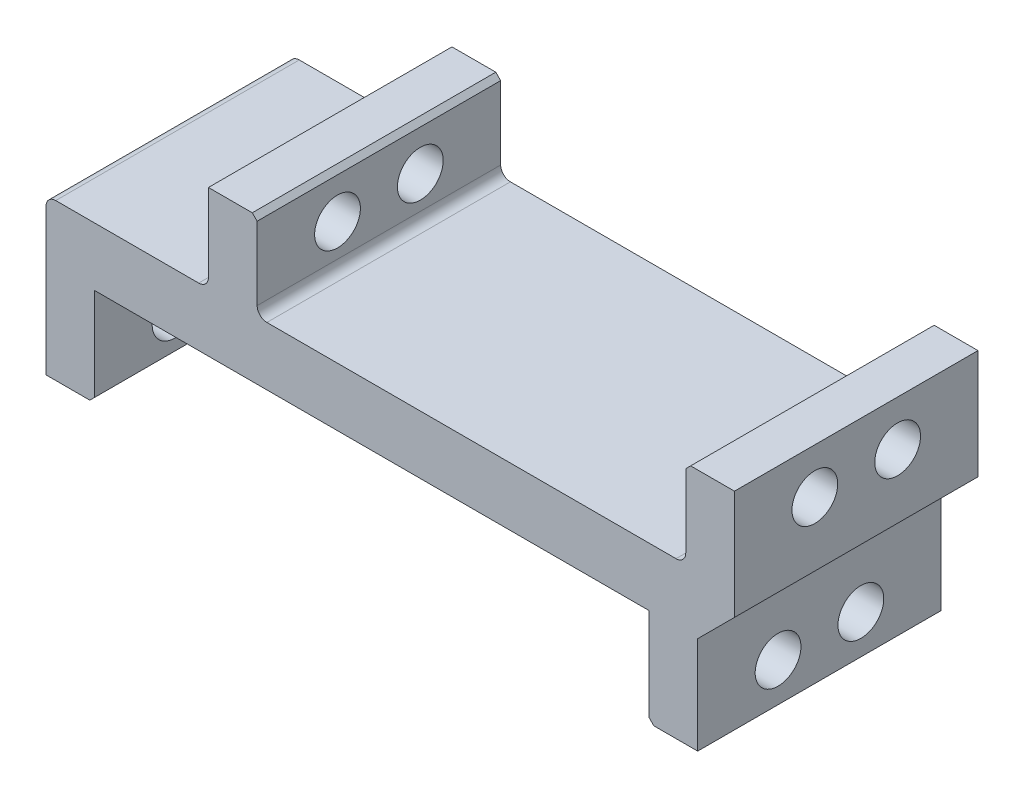
from build123d import *

# Parameters (mm, degrees)
BOSS_EXTRUDE3_DEPTH     = 12.5
SKETCH6_R               = 2.35
CUT_EXTRUDE1_DEPTH      = 38.225
CUT_EXTRUDE1_DEPTH_BACK = 34.45
CHAMFER1_SIZE           = 0.5


with BuildPart() as part:
    # Sketch5 → Boss-Extrude3 (new body, symmetric)
    with BuildSketch(Plane.XY):
        with BuildLine():
            Line((33.45, 0.7), (37.225, 4.475))
            Line((37.225, 4.475), (37.225, 15.7))
            Line((37.225, 15.7), (32.225, 15.7))
            Line((32.225, 15.7), (32.225, 7.7))
            ThreePointArc((32.225, 7.7), (31.932106781, 6.992893219), (31.225, 6.7))
            Line((31.225, 6.7), (-10.775, 6.7))
            ThreePointArc((-10.775, 6.7), (-11.482106781, 6.992893219), (-11.775, 7.7))
            Line((-11.775, 7.7), (-11.775, 15.7))
            Line((-11.775, 15.7), (-16.775, 15.7))
            Line((-16.775, 15.7), (-16.775, 7.7))
            ThreePointArc((-16.775, 7.7), (-17.067893219, 6.992893219), (-17.775, 6.7))
            Line((-17.775, 6.7), (-32.45, 6.7))
            ThreePointArc((-32.45, 6.7), (-33.157106781, 6.407106781), (-33.45, 5.7))
            Line((-33.45, 5.7), (-33.45, -9.3))
            Line((-33.45, -9.3), (-28.45, -9.3))
            Line((-28.45, -9.3), (-28.45, 0.7))
            Line((-28.45, 0.7), (28.45, 0.7))
            Line((28.45, 0.7), (28.45, -9.3))
            Line((28.45, -9.3), (33.45, -9.3))
            Line((33.45, -9.3), (33.45, 0.7))
        make_face()
    extrude(amount=BOSS_EXTRUDE3_DEPTH, both=True)

    # Sketch6 → Cut-Extrude1 (cut, two sides)
    with BuildSketch(Plane(origin=(0, 0, 0), x_dir=(0, 0, -1), z_dir=(1, 0, 0))) as cut_extrude1_sk:
        with Locations((-4.25, 11.05)):
            Circle(SKETCH6_R)
        with Locations((4.25, 11.05)):
            Circle(SKETCH6_R)
        with Locations((4.25, -5.3)):
            Circle(SKETCH6_R)
        with Locations((-4.25, -5.3)):
            Circle(SKETCH6_R)
    extrude(amount=CUT_EXTRUDE1_DEPTH, mode=Mode.SUBTRACT)
    extrude(cut_extrude1_sk.sketch, amount=-CUT_EXTRUDE1_DEPTH_BACK, mode=Mode.SUBTRACT)

    # Chamfer1
    chamfer1_edges = [part.edges().sort_by_distance(p)[0] for p in [
        (-11.775, 15.7, 0),
        (32.225, 15.7, 0),
        (28.45, -9.3, 0),
        (-28.45, -9.3, 0),
    ]]
    chamfer(chamfer1_edges, length=CHAMFER1_SIZE)


solid = part.part
